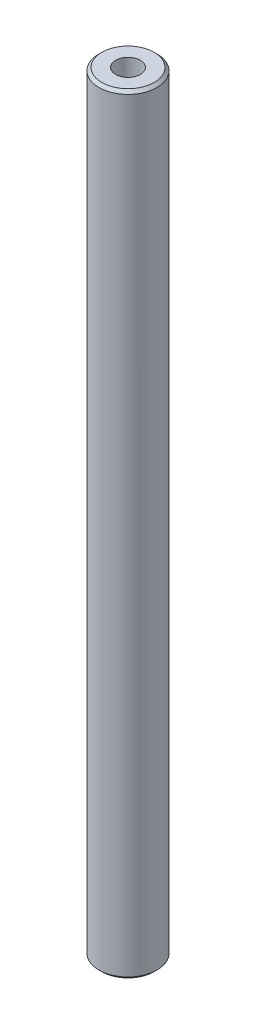
from build123d import *

# Parameters (mm, degrees)
SKETCH1_W     = 10
SKETCH1_H     = 265
CHAMFER1_SIZE = 1


with BuildPart() as part:
    # Sketch1 → Revolve2 (revolve)
    with BuildSketch(Plane.XY):
        with Locations((-5, 0)):
            Rectangle(SKETCH1_W, SKETCH1_H)
    revolve(axis=Axis((0, 132.5, 0), (0, -1, 0)))

    # Sketch3 → M10 Tapped Hole1 (revolve, cut)
    with BuildSketch(Plane(origin=(0, -132.5, 0), x_dir=(0, 0, -1), z_dir=(1, 0, 0))):
        Polygon((0, 0), (0, 27.053657631), (4.25, 24.5), (4.25, 0), align=None)
    m10_tapped_hole1 = revolve(axis=Axis((0, -138.85, 0), (0, 1, 0)), mode=Mode.SUBTRACT)

    # Mirror1: M10 Tapped Hole1 across plane
    add(m10_tapped_hole1.mirror(Plane.ZX), mode=Mode.SUBTRACT)

    # Chamfer1
    chamfer1_edges = [part.edges().sort_by_distance(p)[0] for p in [
        (10, -132.5, 0),
        (10, 132.5, 0),
    ]]
    chamfer(chamfer1_edges, length=CHAMFER1_SIZE)


solid = part.part
